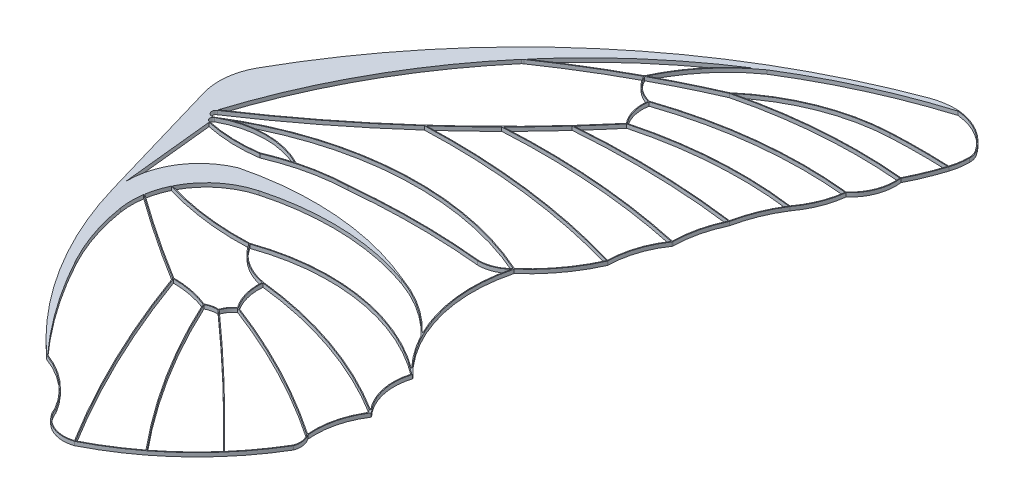
from build123d import *

# Parameters (mm, degrees)
RESSALTO_EXTRUS_O1_DEPTH = 2
ESBO_O3_W                = 13.5
ESBO_O3_H                = 41.75
CORTE_EXTRUS_O2_DEPTH    = 0.2


with BuildPart() as part:
    # Esboço1 → Ressalto-extrusão1 (new body)
    with BuildSketch(Plane(origin=(0, 0, 0), x_dir=(1, 0, 0), z_dir=(0, 1, 0))):
        with BuildLine():
            Line((-2.891885916, -25.331386579), (16.890636414, -92.871950666))
            ThreePointArc((16.890636414, -92.871950666), (39.509715195, -143.24681252), (74.924632392, -185.614643143))
            ThreePointArc((74.924632392, -185.614643143), (90.053250325, -194.317508541), (101.317198447, -207.649365854))
            ThreePointArc((101.317198447, -207.649365854), (109.339932134, -216.703217601), (121.414649078, -217.436496537))
            ThreePointArc((121.414649078, -217.436496537), (121.423131136, -217.432766567), (121.431473842, -217.428734539))
            ThreePointArc((121.431473842, -217.428734539), (155.03526296, -193.949101447), (180.732122887, -162.008857192))
            ThreePointArc((180.732122887, -162.008857192), (181.188239019, -157.584851871), (179.579203123, -153.438664648))
            ThreePointArc((179.579203123, -153.438664648), (180.544757753, -139.671656891), (186.018022228, -127.002553753))
            ThreePointArc((186.018022228, -127.002553753), (186.089619632, -126.716123165), (185.969624565, -126.446364285))
            ThreePointArc((185.969624565, -126.446364285), (179.033051629, -113.383903181), (179.566523634, -98.60353303))
            ThreePointArc((179.566523634, -98.60353303), (179.568845143, -98.494180052), (179.513294894, -98.399958861))
            ThreePointArc((179.513294894, -98.399958861), (158.838253644, -64.171647637), (158.407910237, -24.186032419))
            ThreePointArc((158.407910237, -24.186032419), (170.345122282, -11.218617872), (179.220005433, 4.009229005))
            ThreePointArc((179.220005433, 4.009229005), (179.232638679, 4.047550287), (179.237322945, 4.087627428))
            ThreePointArc((179.237322945, 4.087627428), (181.421355488, 17.384501121), (187.376766076, 29.472095295))
            ThreePointArc((187.376766076, 29.472095295), (187.463240561, 29.647364474), (187.495240153, 29.840167866))
            ThreePointArc((187.495240153, 29.840167866), (189.041723719, 42.177149), (193.176832614, 53.902915046))
            ThreePointArc((193.176832614, 53.902915046), (193.186037336, 53.925638832), (193.192392505, 53.949318131))
            ThreePointArc((193.192392505, 53.949318131), (196.683977717, 65.597702677), (202.212176332, 76.428909901))
            ThreePointArc((202.212176332, 76.428909901), (207.81407221, 86.384811826), (210.665701384, 97.446883587))
            ThreePointArc((210.665701384, 97.446883587), (217.157138995, 106.918422119), (218.517613108, 118.320084919))
            ThreePointArc((218.517613108, 118.320084919), (222.53357195, 127.064851642), (225.828988219, 136.105819626))
            ThreePointArc((225.828988219, 136.105819626), (226.936116515, 140.796582456), (227.308114084, 145.601851107))
            ThreePointArc((227.308114084, 145.601851107), (226.92415432, 148.202079294), (225.805048795, 150.58035904))
            ThreePointArc((225.805048795, 150.58035904), (216.132997815, 159.854580332), (203.432149719, 164.126372503))
            ThreePointArc((203.432149719, 164.126372503), (196.305976757, 163.870755082), (189.397159866, 162.105555232))
            ThreePointArc((189.397159866, 162.105555232), (80.341988523, 97.826401656), (0, 0))
            ThreePointArc((0, 0), (-4.004170085, -12.373640544), (-2.891885916, -25.331386579))
        make_face()
        with BuildLine():
            ThreePointArc((75.061191815, -185.238675693), (55.710509097, -160.996401051), (39.414410112, -134.60371344))
            ThreePointArc((39.414410112, -134.60371344), (32.024240404, -117.575549791), (27.564899418, -99.556469804))
            ThreePointArc((27.564899418, -99.556469804), (27.068868432, -93.446906914), (27.530070276, -87.334616156))
            ThreePointArc((27.530070276, -87.334616156), (50.023709071, -102.94081443), (73.078069491, -117.706100627))
            ThreePointArc((73.078069491, -117.706100627), (94.455943613, -168.678582058), (121.038273811, -217.140805352))
            ThreePointArc((121.038273811, -217.140805352), (109.381253065, -216.277627559), (101.682640282, -207.482028103))
            ThreePointArc((101.682640282, -207.482028103), (90.32477142, -194.023121535), (75.061191815, -185.238675693))
        make_face(mode=Mode.SUBTRACT)
        with BuildLine():
            ThreePointArc((144.073565841, -202.71747677), (133.074913856, -210.37840662), (121.414649077, -216.988884436))
            ThreePointArc((121.414649077, -216.988884436), (94.877808499, -168.632444086), (73.527113878, -117.772862193))
            ThreePointArc((73.527113878, -117.772862193), (83.369797481, -118.753083082), (92.849554804, -121.576813702))
            ThreePointArc((92.849554804, -121.576813702), (115.816888065, -163.816723913), (144.073565841, -202.71747677))
        make_face(mode=Mode.SUBTRACT)
        with BuildLine():
            ThreePointArc((11.879579324, -37.059994062), (10.253925603, -35.789100329), (11.070359275, -33.894012744))
            ThreePointArc((11.070359275, -33.894012744), (31.766860679, -28.367665282), (52.618625636, -33.275779462))
            ThreePointArc((52.618625636, -33.275779462), (45.854920305, -35.402452346), (39.251467246, -37.984090401))
            ThreePointArc((39.251467246, -37.984090401), (25.524465377, -38.738184329), (11.879579324, -37.059994062))
        make_face(mode=Mode.SUBTRACT)
        with BuildLine():
            ThreePointArc((30.954862617, -76.306512457), (53.928434843, -81.142970387), (77.385630644, -82.110602151))
            ThreePointArc((77.385630644, -82.110602151), (86.442113829, -91.376407189), (98.476067628, -96.178384559))
            ThreePointArc((98.476067628, -96.178384559), (99.325868559, -105.523547237), (103.329588684, -114.010269354))
            ThreePointArc((103.329588684, -114.010269354), (100.839320134, -116.575545142), (99.274681475, -119.790196472))
            ThreePointArc((99.274681475, -119.790196472), (96.035057019, -120.070400422), (92.986045613, -121.200537717))
            ThreePointArc((92.986045613, -121.200537717), (83.327149533, -118.337154453), (73.29906303, -117.372417034))
            ThreePointArc((73.29906303, -117.372417034), (50.20912985, -102.583681626), (27.682018255, -86.950993041))
            ThreePointArc((27.682018255, -86.950993041), (27.640126359, -86.915622588), (27.604076284, -86.874314091))
            ThreePointArc((27.604076284, -86.874314091), (28.904488661, -81.471516217), (30.954862617, -76.306512457))
        make_face(mode=Mode.SUBTRACT)
        with BuildLine():
            Line((16.890636414, -86.132821), (11.85931196, -37.464698075))
            ThreePointArc((11.85931196, -37.464698075), (25.569939965, -39.139925167), (39.361189646, -38.372371707))
            ThreePointArc((39.361189646, -38.372371707), (57.801285112, -32.389959226), (77.032122973, -29.940213308))
            ThreePointArc((77.032122973, -29.940213308), (111.045550918, -28.261906009), (145.058243072, -29.955059416))
            ThreePointArc((145.058243072, -29.955059416), (151.973262614, -28.636570967), (157.848232778, -24.758345519))
            ThreePointArc((157.848232778, -24.758345519), (155.983137797, -51.598831019), (163.541497745, -77.420555131))
            ThreePointArc((163.541497745, -77.420555131), (149.854946418, -65.924493525), (133.842737694, -57.981553802))
            ThreePointArc((133.842737694, -57.981553802), (87.670250354, -46.538605901), (40.261886529, -50.448424731))
            ThreePointArc((40.261886529, -50.448424731), (23.057242833, -64.675979535), (16.890636414, -86.132821))
        make_face(mode=Mode.SUBTRACT)
        with BuildLine():
            ThreePointArc((31.132626071, -75.942156085), (41.348809985, -63.051320172), (55.949990062, -55.478367997))
            ThreePointArc((55.949990062, -55.478367997), (95.05027781, -50.955008797), (133.708809753, -58.358466666))
            ThreePointArc((133.708809753, -58.358466666), (149.927402921, -66.450957854), (163.72457307, -78.205500545))
            ThreePointArc((163.72457307, -78.205500545), (163.984765643, -78.494020984), (164.23916715, -78.787660375))
            ThreePointArc((164.23916715, -78.787660375), (169.918511042, -87.993064481), (176.841349297, -96.30382391))
            ThreePointArc((176.841349297, -96.30382391), (128.956486326, -76.690746726), (77.454382768, -81.707341939))
            ThreePointArc((77.454382768, -81.707341939), (54.053212131, -80.755434548), (31.132626071, -75.942156085))
        make_face(mode=Mode.SUBTRACT)
        with BuildLine():
            ThreePointArc((144.390735312, -202.473293628), (116.188479484, -163.656017033), (93.258837749, -121.508897014))
            ThreePointArc((93.258837749, -121.508897014), (96.210985678, -120.441238679), (99.340524238, -120.194135217))
            ThreePointArc((99.340524238, -120.194135217), (132.717797326, -151.058354618), (164.973783051, -183.092614136))
            ThreePointArc((164.973783051, -183.092614136), (155.156655203, -193.286781209), (144.390735312, -202.473293628))
        make_face(mode=Mode.SUBTRACT)
        with BuildLine():
            ThreePointArc((165.237327428, -182.789851396), (133.00300151, -150.777649689), (99.649253017, -119.933520799))
            ThreePointArc((99.649253017, -119.933520799), (101.18300434, -116.782199542), (103.6372122, -114.280183841))
            ThreePointArc((103.6372122, -114.280183841), (142.598272069, -131.743297777), (179.242488543, -153.655073914))
            ThreePointArc((179.242488543, -153.655073914), (180.78822356, -157.611813736), (180.367828424, -161.838911403))
            ThreePointArc((180.367828424, -161.838911403), (173.27117969, -172.652799603), (165.237327428, -182.789851396))
        make_face(mode=Mode.SUBTRACT)
        with BuildLine():
            ThreePointArc((179.145908385, -153.10569005), (142.589295312, -131.287701646), (103.734386544, -113.889234988))
            ThreePointArc((103.734386544, -113.889234988), (99.732427529, -105.493744387), (98.872883702, -96.233014243))
            ThreePointArc((98.872883702, -96.233014243), (143.098520561, -106.179072223), (183.998274189, -125.724945907))
            ThreePointArc((183.998274189, -125.724945907), (184.88113455, -126.943403006), (184.664770288, -128.432451905))
            ThreePointArc((184.664770288, -128.432451905), (179.978340813, -140.338043697), (179.145908385, -153.10569005))
        make_face(mode=Mode.SUBTRACT)
        with BuildLine():
            ThreePointArc((98.718726209, -95.813871314), (86.794460768, -91.13013492), (77.796430253, -82.0108729))
            ThreePointArc((77.796430253, -82.0108729), (130.390825581, -77.316445759), (178.842177575, -98.308695665))
            ThreePointArc((178.842177575, -98.308695665), (179.042636723, -98.592893915), (179.048514046, -98.940626531))
            ThreePointArc((179.048514046, -98.940626531), (178.557910182, -113.090704042), (184.838939896, -125.779835275))
            ThreePointArc((184.838939896, -125.779835275), (143.48611956, -105.890223927), (98.718726209, -95.813871314))
        make_face(mode=Mode.SUBTRACT)
        with BuildLine():
            ThreePointArc((77.00571445, -29.540870677), (64.991382888, -30.640116345), (53.184593307, -33.120484))
            ThreePointArc((53.184593307, -33.120484), (34.997673911, -28.037667048), (16.344111956, -30.977682642))
            ThreePointArc((16.344111956, -30.977682642), (86.294442644, -10.497166778), (157.8926845, -24.142387796))
            ThreePointArc((157.8926845, -24.142387796), (152.04587989, -28.173512381), (145.079823263, -29.555230382))
            ThreePointArc((145.079823263, -29.555230382), (111.043124536, -27.861905479), (77.00571445, -29.540870677))
        make_face(mode=Mode.SUBTRACT)
        with BuildLine():
            ThreePointArc((10.884162093, -33.792177396), (7.936541731, -32.891512454), (8.646375466, -29.892212669))
            ThreePointArc((8.646375466, -29.892212669), (40.102456108, -7.368908744), (69.841232126, 17.377594644))
            ThreePointArc((69.841232126, 17.377594644), (124.842337918, 15.064533704), (178.761046703, 3.962969299))
            ThreePointArc((178.761046703, 3.962969299), (169.975242199, -11.046105684), (158.195344978, -23.840507352))
            ThreePointArc((158.195344978, -23.840507352), (83.286903321, -10.270827271), (10.884162093, -33.792177396))
        make_face(mode=Mode.SUBTRACT)
        with BuildLine():
            ThreePointArc((65.163327011, 72.986151676), (65.512554625, 73.261919505), (65.873725431, 73.521849244))
            ThreePointArc((65.873725431, 73.521849244), (85.034977645, 85.921559119), (104.841521177, 97.262071658))
            ThreePointArc((104.841521177, 97.262071658), (110.028306452, 90.798172973), (117.42803317, 87.066045938))
            ThreePointArc((117.42803317, 87.066045938), (117.855262612, 78.759779692), (121.642967981, 71.355060116))
            ThreePointArc((121.642967981, 71.355060116), (68.727790014, 16.919047723), (8.608266137, -29.43759531))
            ThreePointArc((8.608266137, -29.43759531), (31.751463387, 24.609289931), (65.163327011, 72.986151676))
        make_face(mode=Mode.SUBTRACT)
        with BuildLine():
            ThreePointArc((130.105906511, 129.878932118), (115.574418721, 115.248461285), (104.7762631, 97.681029789))
            ThreePointArc((104.7762631, 97.681029789), (85.206415837, 86.494114614), (66.264337516, 74.274308482))
            ThreePointArc((66.264337516, 74.274308482), (96.177838084, 104.381251589), (130.105906511, 129.878932118))
        make_face(mode=Mode.SUBTRACT)
        with BuildLine():
            ThreePointArc((178.842127699, 4.355978275), (125.114397795, 15.433974602), (70.307334653, 17.795498029))
            ThreePointArc((70.307334653, 17.795498029), (80.610470403, 27.291705844), (90.660333167, 37.055558956))
            ThreePointArc((90.660333167, 37.055558956), (139.066008112, 36.613044124), (186.958653653, 29.570339432))
            ThreePointArc((186.958653653, 29.570339432), (181.056540683, 17.556695855), (178.842127699, 4.355978275))
        make_face(mode=Mode.SUBTRACT)
        with BuildLine():
            ThreePointArc((192.697680535, 53.826703734), (188.632596088, 42.184795574), (187.097186474, 29.949540999))
            ThreePointArc((187.097186474, 29.949540999), (139.348979985, 36.992165146), (91.086670247, 37.481283297))
            ThreePointArc((91.086670247, 37.481283297), (100.008574142, 46.616810225), (108.708987791, 55.963522143))
            ThreePointArc((108.708987791, 55.963522143), (150.759305033, 57.095075342), (192.697680535, 53.826703734))
        make_face(mode=Mode.SUBTRACT)
        with BuildLine():
            ThreePointArc((122.015582584, 71.176571043), (161.60786351, 77.700482874), (201.712469543, 76.384918569))
            ThreePointArc((201.712469543, 76.384918569), (196.290949467, 65.692265225), (192.837884131, 54.211757605))
            ThreePointArc((192.837884131, 54.211757605), (151.026567478, 57.488322955), (109.101297358, 56.395708613))
            ThreePointArc((109.101297358, 56.395708613), (115.62650859, 63.726667144), (122.015582584, 71.176571043))
        make_face(mode=Mode.SUBTRACT)
        with BuildLine():
            ThreePointArc((201.957251989, 76.756062495), (161.711502037, 78.108067884), (121.975723187, 71.579960434))
            ThreePointArc((121.975723187, 71.579960434), (118.238216137, 78.876060323), (117.832890254, 87.063718319))
            ThreePointArc((117.832890254, 87.063718319), (163.48468813, 97.222424933), (210.25288905, 97.368547957))
            ThreePointArc((210.25288905, 97.368547957), (207.439428108, 86.525283804), (201.957251989, 76.756062495))
        make_face(mode=Mode.SUBTRACT)
        with BuildLine():
            ThreePointArc((105.194171334, 97.451237144), (119.956691333, 104.989862866), (135.00518658, 111.940090583))
            ThreePointArc((135.00518658, 111.940090583), (176.305917901, 118.563594016), (218.132560685, 118.172238852))
            ThreePointArc((218.132560685, 118.172238852), (216.767534509, 107.01891476), (210.409374715, 97.754264805))
            ThreePointArc((210.409374715, 97.754264805), (163.467402557, 97.622974649), (117.64681506, 87.422986968))
            ThreePointArc((117.64681506, 87.422986968), (110.323017386, 91.074314456), (105.194171334, 97.451237144))
        make_face(mode=Mode.SUBTRACT)
        with BuildLine():
            ThreePointArc((134.231187047, 132.489001443), (167.471686306, 150.296359156), (202.714101827, 163.712950676))
            ThreePointArc((202.714101827, 163.712950676), (203.051769924, 163.742347016), (203.390434406, 163.728553659))
            ThreePointArc((203.390434406, 163.728553659), (215.925826131, 159.51241094), (225.471877456, 150.359006698))
            ThreePointArc((225.471877456, 150.359006698), (226.541225779, 148.086469034), (226.908114084, 145.601851107))
            ThreePointArc((226.908114084, 145.601851107), (226.552562533, 140.93374904), (225.494110918, 136.373346207))
            ThreePointArc((225.494110918, 136.373346207), (210.329945011, 136.70097858), (195.166849247, 136.327083543))
            ThreePointArc((195.166849247, 136.327083543), (162.992204891, 129.355762587), (134.832810466, 112.301274588))
            ThreePointArc((134.832810466, 112.301274588), (119.960236596, 105.436275442), (105.366397335, 97.997087152))
            ThreePointArc((105.366397335, 97.997087152), (117.587042911, 117.093961509), (134.231187047, 132.489001443))
        make_face(mode=Mode.SUBTRACT)
        with BuildLine():
            ThreePointArc((218.195023717, 118.568133932), (176.701785201, 118.994028297), (135.713472408, 112.526537053))
            ThreePointArc((135.713472408, 112.526537053), (163.518917342, 129.134060421), (195.18595438, 135.927540062))
            ThreePointArc((195.18595438, 135.927540062), (210.276471462, 136.300892078), (225.368164637, 135.97856519))
            ThreePointArc((225.368164637, 135.97856519), (222.128079781, 127.130596632), (218.195023717, 118.568133932))
        make_face(mode=Mode.SUBTRACT)
    extrude(amount=RESSALTO_EXTRUS_O1_DEPTH)

    # Esboço3 → Corte-extrusão2 (cut)
    with BuildSketch(Plane(origin=(0, 0, 0), x_dir=(1, 0, 0), z_dir=(0, 1, 0))):
        with Locations((1.25, -9.755)):
            Rectangle(ESBO_O3_W, ESBO_O3_H)
    extrude(amount=CORTE_EXTRUS_O2_DEPTH, mode=Mode.SUBTRACT)


solid = part.part
